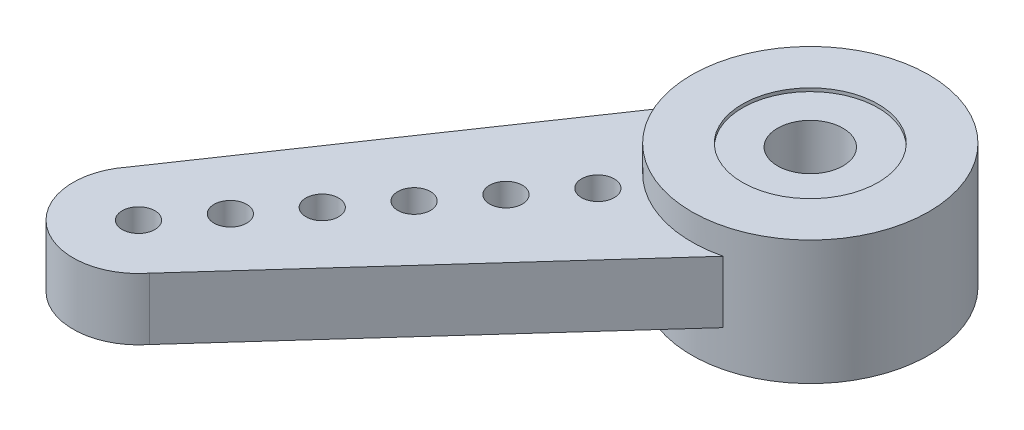
from build123d import *

# Parameters (mm, degrees)
SKETCH1_R           = 3.625
SKETCH1_R_2         = 2.075
BOSS_EXTRUDE1_DEPTH = 2.41
SKETCH2_R           = 1
SKETCH2_R_2         = 0.5
BOSS_EXTRUDE3_DEPTH = 1.89
BOSS_EXTRUDE4_START = 4.3
SKETCH1_2_R         = 3.625
SKETCH1_2_R_2       = 2.075
BOSS_EXTRUDE4_DEPTH = 0.8
SKETCH3_R           = 3.625
SKETCH3_R_2         = 2.075
CUT_EXTRUDE1_DEPTH  = 1.3
SKETCH4_R           = 2.075
SKETCH4_R_2         = 1
BOSS_EXTRUDE5_DEPTH = 0.7
SKETCH5_R           = 2.075
SKETCH5_R_2         = 1
CUT_EXTRUDE2_DEPTH  = 1


with BuildPart() as part:
    # Sketch1 → Boss-Extrude1 (new body)
    with BuildSketch(Plane(origin=(0, 0, 0), x_dir=(1, 0, 0), z_dir=(0, 1, 0))):
        with Locations(Location((0, 0, 0), (0, 0, 270))):
            Circle(SKETCH1_R)
        with Locations(Location((0, 0, 0), (0, 0, 270))):
            Circle(SKETCH1_R_2, mode=Mode.SUBTRACT)
    extrude(amount=BOSS_EXTRUDE1_DEPTH)

    # Sketch2 → Boss-Extrude3 (add)
    with BuildSketch(Plane(origin=(0, 2.41, 0), x_dir=(1, 0, 0), z_dir=(0, 1, 0))):
        with BuildLine():
            Line((-10.6054557, -10.267177528), (-3.625, 0))
            ThreePointArc((-3.625, 0), (2.238819707, 2.851019347), (0.859585555, -3.521610097))
            Line((0.859585555, -3.521610097), (-7.459503317, -12.737599274))
            ThreePointArc((-7.459503317, -12.737599274), (-10.267690381, -13.075364593), (-10.6054557, -10.267177528))
        make_face()
        with Locations(Location((0, 0, 0), (0, 0, 270))):
            Circle(SKETCH2_R, mode=Mode.SUBTRACT)
        with Locations(Location((-9.032479508, -11.502388401, 0), (0, 0, 270))):
            Circle(SKETCH2_R_2, mode=Mode.SUBTRACT)
        with Locations(Location((-7.797268635, -9.92941221, 0), (0, 0, 270))):
            Circle(SKETCH2_R_2, mode=Mode.SUBTRACT)
        with Locations(Location((-6.562057762, -8.356436018, 0), (0, 0, 270))):
            Circle(SKETCH2_R_2, mode=Mode.SUBTRACT)
        with Locations(Location((-5.32684689, -6.783459826, 0), (0, 0, 270))):
            Circle(SKETCH2_R_2, mode=Mode.SUBTRACT)
        with Locations(Location((-4.091636017, -5.210483635, 0), (0, 0, 270))):
            Circle(SKETCH2_R_2, mode=Mode.SUBTRACT)
        with Locations(Location((-2.856425144, -3.637507443, 0), (0, 0, 270))):
            Circle(SKETCH2_R_2, mode=Mode.SUBTRACT)
    extrude(amount=BOSS_EXTRUDE3_DEPTH)

    # Sketch1_2 → Boss-Extrude4 (add)
    with BuildSketch(Plane(origin=(0, 0, 0), x_dir=(1, 0, 0), z_dir=(0, 1, 0)).offset(BOSS_EXTRUDE4_START)):
        with Locations(Location((0, 0, 0), (0, 0, 270))):
            Circle(SKETCH1_2_R)
        with Locations(Location((0, 0, 0), (0, 0, 270))):
            Circle(SKETCH1_2_R_2, mode=Mode.SUBTRACT)
    extrude(amount=BOSS_EXTRUDE4_DEPTH)

    # Sketch3 → Cut-Extrude1 (cut)
    with BuildSketch(Plane.XZ):
        with Locations(Location((0, 0, 0), (0, 0, 270))):
            Circle(SKETCH3_R)
        with Locations(Location((0, 0, 0), (0, 0, 270))):
            Circle(SKETCH3_R_2, mode=Mode.SUBTRACT)
    extrude(amount=-CUT_EXTRUDE1_DEPTH, mode=Mode.SUBTRACT)

    # Sketch4 → Boss-Extrude5 (add)
    with BuildSketch(Plane(origin=(0, 4.3, 0), x_dir=(1, 0, 0), z_dir=(0, 1, 0))):
        with Locations(Location((0, 0, 0), (0, 0, 90))):
            Circle(SKETCH4_R)
        with Locations(Location((0, 0, 0), (0, 0, 270))):
            Circle(SKETCH4_R_2, mode=Mode.SUBTRACT)
    extrude(amount=BOSS_EXTRUDE5_DEPTH)

    # Sketch5 → Cut-Extrude2 (cut)
    with BuildSketch(Plane.XZ.offset(-2.41)):
        with Locations(Location((0, 0, 0), (0, 0, 270))):
            Circle(SKETCH5_R)
        with Locations(Location((0, 0, 0), (0, 0, 270))):
            Circle(SKETCH5_R_2, mode=Mode.SUBTRACT)
    extrude(amount=-CUT_EXTRUDE2_DEPTH, mode=Mode.SUBTRACT)


solid = part.part
